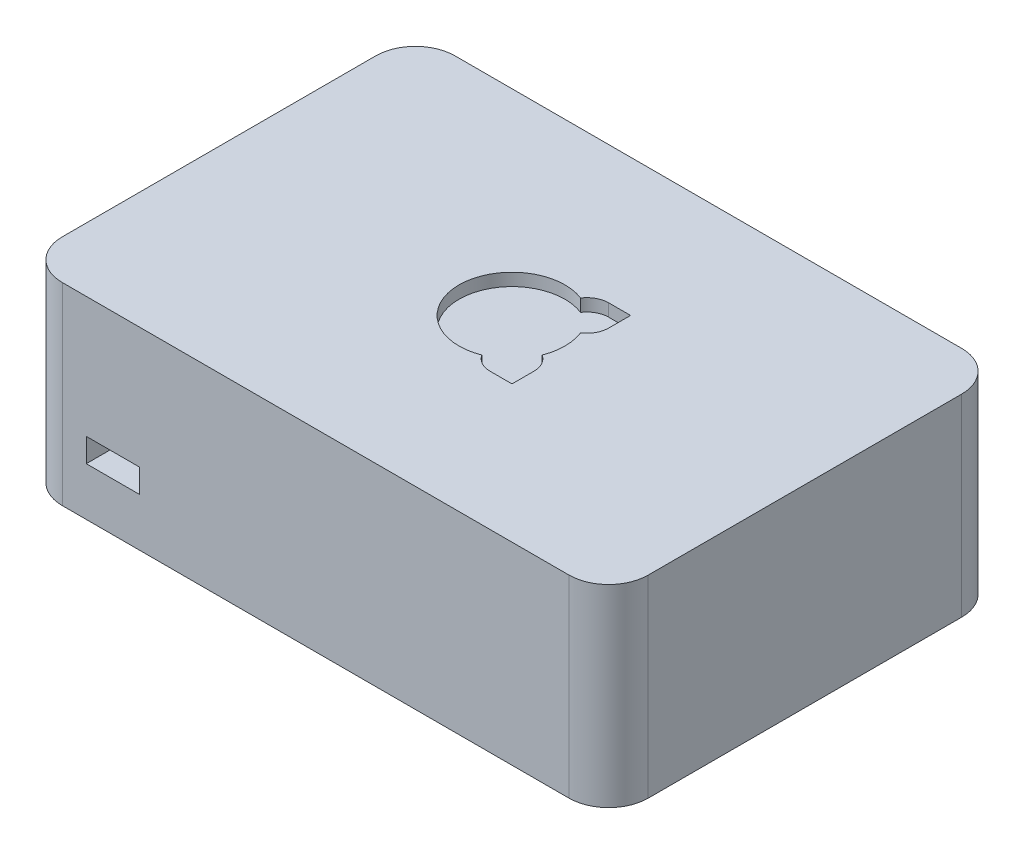
from build123d import *

# Parameters (mm, degrees)
SKETCH1_W           = 94
SKETCH1_H           = 63
BOSS_EXTRUDE1_DEPTH = 31
FILLET1_R           = 6.35
SKETCH3_W           = 50.5
SKETCH3_H           = 2
BOSS_EXTRUDE2_DEPTH = 2.5
SKETCH4_W           = 8.5
SKETCH4_H           = 3.8
CUT_EXTRUDE1_DEPTH  = 8
SKETCH5_R           = 8.5
SKETCH5_R_2         = 3.5
SKETCH5_W           = 3.5
SKETCH5_H           = 3.5
CUT_EXTRUDE2_DEPTH  = 2
SKETCH6_R           = 1.5875
CUT_EXTRUDE3_DEPTH  = 5


with BuildPart() as part:
    # Sketch1 → Boss-Extrude1 (new body)
    with BuildSketch(Plane(origin=(0, 0, 0), x_dir=(1, 0, 0), z_dir=(0, 1, 0))):
        with Locations((47, 31.5)):
            Rectangle(SKETCH1_W, SKETCH1_H)
    extrude(amount=BOSS_EXTRUDE1_DEPTH)

    # Fillet1
    fillet1_edges = [part.edges().sort_by_distance(p)[0] for p in [
        (0, 15.5, 0),
        (0, 15.5, -63),
        (94, 15.5, -63),
        (94, 15.5, 0),
    ]]
    fillet(fillet1_edges, radius=FILLET1_R)

    # Sketch3 → Boss-Extrude2 (add)
    with BuildSketch(Plane(origin=(0, 0, -63), x_dir=(-1, 0, 0), z_dir=(0, 0, -1))):
        with Locations((-37.25, 27.46)):
            Rectangle(SKETCH3_W, SKETCH3_H)
    extrude(amount=BOSS_EXTRUDE2_DEPTH)

    # Sketch4 → Cut-Extrude1 (cut)
    with BuildSketch(Plane.XY):
        with Locations((14.45, 9.65)):
            Rectangle(SKETCH4_W, SKETCH4_H)
    extrude(amount=-CUT_EXTRUDE1_DEPTH, mode=Mode.SUBTRACT)

    # Sketch5 → Cut-Extrude2 (cut)
    with BuildSketch(Plane(origin=(0, 31, 0), x_dir=(1, 0, 0), z_dir=(0, 1, 0))):
        with Locations((47, 31.5)):
            Circle(SKETCH5_R)
        with Locations((53.01040764, 37.51040764)):
            Circle(SKETCH5_R_2)
        with Locations((53.01040764, 25.48959236)):
            Circle(SKETCH5_R_2)
        with Locations((54.76040764, 39.26040764)):
            Rectangle(SKETCH5_W, SKETCH5_H)
        with Locations((54.76040764, 23.73959236)):
            Rectangle(SKETCH5_W, SKETCH5_H)
    extrude(amount=-CUT_EXTRUDE2_DEPTH, mode=Mode.SUBTRACT)

    # Sketch6 → Cut-Extrude3 (cut)
    with BuildSketch(Plane.XZ):
        with Locations((27.2, -31.5)):
            Circle(SKETCH6_R)
        with Locations((79, -31.5)):
            Circle(SKETCH6_R)
    extrude(amount=-CUT_EXTRUDE3_DEPTH, mode=Mode.SUBTRACT)


solid = part.part
